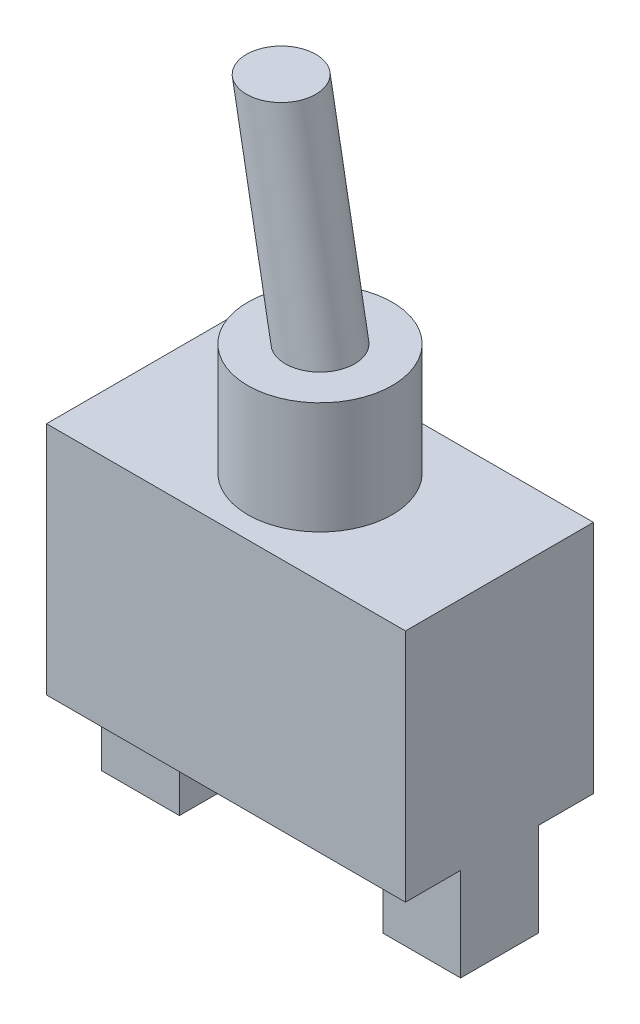
from build123d import *

# Parameters (mm, degrees)
SKETCH1_W           = 29.337
SKETCH1_H           = 15.367
BOSS_EXTRUDE1_DEPTH = 19.2024
SKETCH2_R           = 5.9055
BOSS_EXTRUDE2_DEPTH = 9.144
SKETCH3_W           = 6.35
SKETCH3_H           = 6.35
BOSS_EXTRUDE3_DEPTH = 7.62
SKETCH4_R           = 2.8321


with BuildPart() as part:
    # Sketch1 → Boss-Extrude1 (new body)
    with BuildSketch(Plane(origin=(0, 0, 0), x_dir=(1, 0, 0), z_dir=(0, 1, 0))):
        Rectangle(SKETCH1_W, SKETCH1_H)
    extrude(amount=BOSS_EXTRUDE1_DEPTH)

    # Sketch2 → Boss-Extrude2 (add)
    with BuildSketch(Plane(origin=(0, 19.2024, 0), x_dir=(1, 0, 0), z_dir=(0, 1, 0))):
        Circle(SKETCH2_R)
    extrude(amount=BOSS_EXTRUDE2_DEPTH)

    # Sketch3 → Boss-Extrude3 (add)
    with BuildSketch(Plane.XZ):
        with Locations((-11.4935, 0)):
            Rectangle(SKETCH3_W, SKETCH3_H)
        with Locations((11.4935, 0)):
            Rectangle(SKETCH3_W, SKETCH3_H)
    extrude(amount=BOSS_EXTRUDE3_DEPTH)

    # Sweep1: sweep along a path in Sketch5
    with BuildLine(Plane.XY) as sweep1_path:
        Line((0, 28.3464), (-3.175, 45.840621189))
    # Sketch4 → Sweep1 (sweep)
    with BuildSketch(Plane(origin=(0, 28.3464, 0), x_dir=(1, 0, 0), z_dir=(0, 1, 0))):
        Circle(SKETCH4_R)
    sweep(path=sweep1_path.line)


solid = part.part
